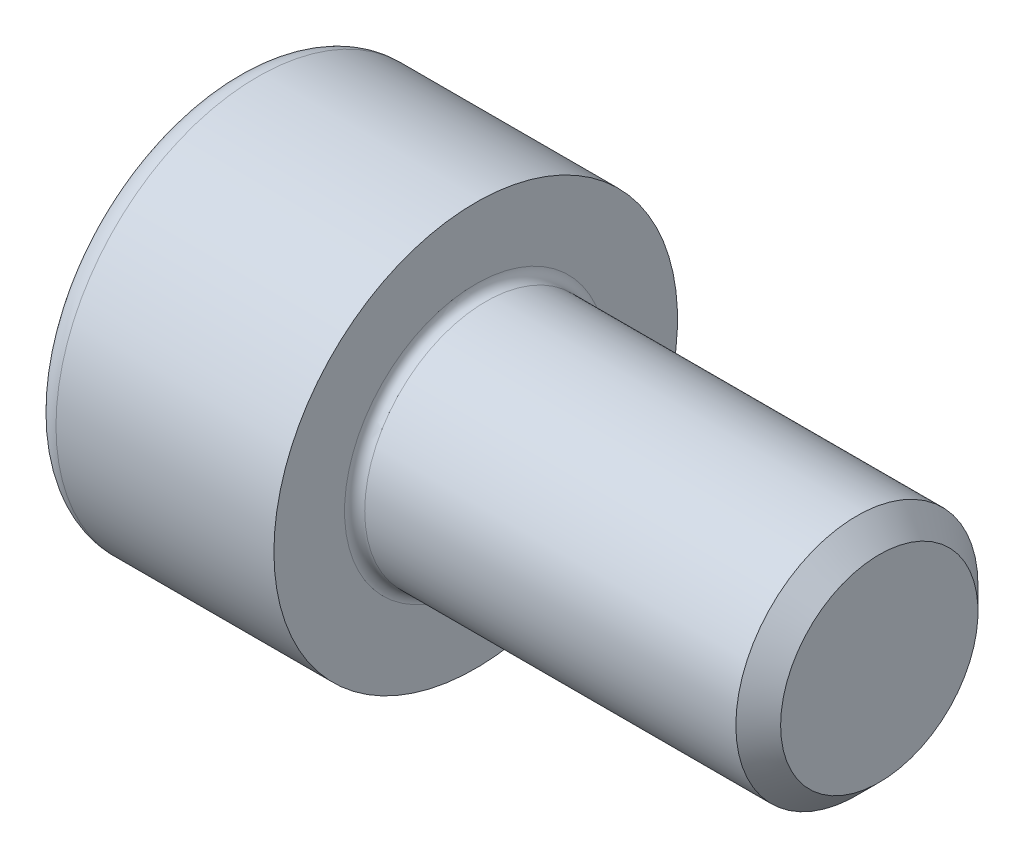
from build123d import *

# Parameters (mm, degrees)
FILLET1_R   = 0.25
FILLET2_R   = 0.6
HEX_2_DEPTH = 3


with BuildPart() as part:
    # BodySke → Base-Revolve (revolve)
    with BuildSketch(Plane.XY):
        Polygon((0, 0), (0, 5), (6, 5), (6, 3), (15.4455, 3), (16, 2.4455), (16, 0), align=None)
    revolve(axis=Axis((-31.75, 0, 0), (1, 0, 0)))

    # Fillet1
    fillet1_edges = [part.edges().sort_by_distance(p)[0] for p in [
        (6, -3, 0),
    ]]
    fillet(fillet1_edges, radius=FILLET1_R)

    # Fillet2
    fillet2_edges = [part.edges().sort_by_distance(p)[0] for p in [
        (0, -5, 0),
    ]]
    fillet(fillet2_edges, radius=FILLET2_R)

    # Sketch2 → Hex-PreBroach (revolve, cut)
    with BuildSketch(Plane.XY):
        Polygon((0, 2.51), (3, 2.51), (4.449149176, 0), (0, 0), align=None)
    revolve(axis=Axis((0, 0, 0), (1, 0, 0)), mode=Mode.SUBTRACT)

    # Sketch3 → Hex 2 (cut)
    with BuildSketch(Plane(origin=(0, 0, 0), x_dir=(0, 0.5, 0.866025404), z_dir=(-1, 0, 0))):
        Polygon((1.449149176, 2.51), (-1.449149176, 2.51), (-2.898298351, 0), (-1.449149176, -2.51), (1.449149176, -2.51), (2.898298351, 0), align=None)
    extrude(amount=-HEX_2_DEPTH, mode=Mode.SUBTRACT)


solid = part.part
